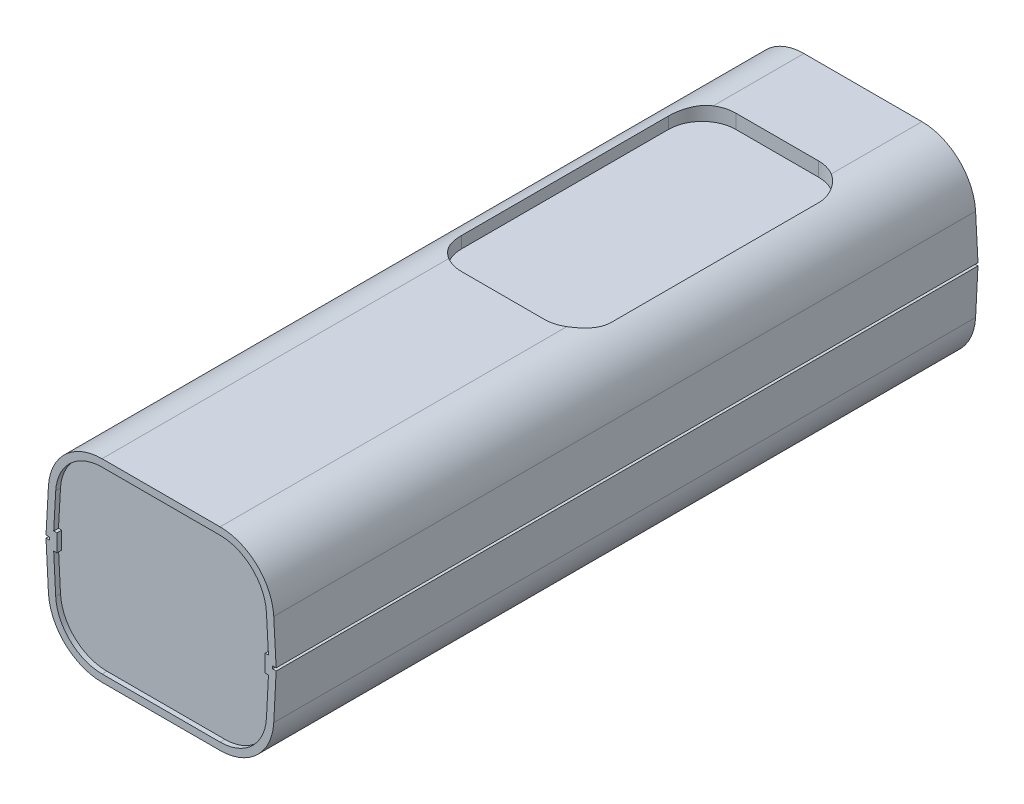
from build123d import *

# Parameters (mm, degrees)
MAIN_BODY_DEPTH  = 77
LENS_CUT_DEPTH   = 3.1
END_RECESS_START = -77
END_RECESS_DEPTH = 1.05


with BuildPart() as part:
    # main_features_sketch → main_body (new, symmetric)
    with BuildSketch(Plane.XY):
        with BuildLine():
            ThreePointArc((24.721981093, -10.075200948), (21.063236898, -18.011630623), (12.946199947, -21.25))
            Line((12.946199947, -21.25), (-12.946199947, -21.25))
            ThreePointArc((-12.946199947, -21.25), (-21.063236898, -18.011630623), (-24.721981093, -10.075200948))
            Line((-24.721981093, -10.075200948), (-25.25, 0))
            Line((-25.25, 0), (-24.45, 0))
            Line((-24.45, 0), (-24.45, 0.6))
            Line((-24.45, 0.6), (-25.25, 0.6))
            Line((-25.25, 0.6), (-24.719878978, 10.11408323))
            ThreePointArc((-24.719878978, 10.11408323), (-21.049103134, 18.025020906), (-12.946199947, 21.25))
            Line((-12.946199947, 21.25), (12.946199947, 21.25))
            ThreePointArc((12.946199947, 21.25), (21.049103134, 18.025020906), (24.719878978, 10.11408323))
            Line((24.719878978, 10.11408323), (25.25, 0.6))
            Line((25.25, 0.6), (24.45, 0.6))
            Line((24.45, 0.6), (24.45, 0))
            Line((24.45, 0), (25.25, 0))
            Line((25.25, 0), (24.721981093, -10.075200948))
        make_face()
        with BuildLine():
            ThreePointArc((-23.124173837, -9.991463418), (-19.961869577, -16.85103163), (-12.946199947, -19.65))
            Line((-12.946199947, -19.65), (12.946199947, -19.65))
            ThreePointArc((12.946199947, -19.65), (19.961869577, -16.85103163), (23.124173837, -9.991463418))
            Line((23.124173837, -9.991463418), (23.5639518, -1.6))
            Line((23.5639518, -1.6), (22.85, -1.6))
            Line((22.85, -1.6), (22.85, 2.2))
            Line((22.85, 2.2), (23.558366806, 2.2))
            Line((23.558366806, 2.2), (23.12235695, 10.025069924))
            ThreePointArc((23.12235695, 10.025069924), (19.949653565, 16.86260504), (12.946199947, 19.65))
            Line((12.946199947, 19.65), (-12.946199947, 19.65))
            ThreePointArc((-12.946199947, 19.65), (-19.949653565, 16.86260504), (-23.12235695, 10.025069924))
            Line((-23.12235695, 10.025069924), (-23.558366806, 2.2))
            Line((-23.558366806, 2.2), (-22.85, 2.2))
            Line((-22.85, 2.2), (-22.85, -1.6))
            Line((-22.85, -1.6), (-23.5639518, -1.6))
            Line((-23.5639518, -1.6), (-23.124173837, -9.991463418))
        make_face(mode=Mode.SUBTRACT)
        with BuildLine():
            Line((-23.5639518, -1.6), (-23.124173837, -9.991463418))
            ThreePointArc((-23.124173837, -9.991463418), (-19.961869577, -16.85103163), (-12.946199947, -19.65))
            Line((-12.946199947, -19.65), (12.946199947, -19.65))
            ThreePointArc((12.946199947, -19.65), (19.961869577, -16.85103163), (23.124173837, -9.991463418))
            Line((23.124173837, -9.991463418), (23.5639518, -1.6))
            Line((23.5639518, -1.6), (22.85, -1.6))
            Line((22.85, -1.6), (22.85, 2.2))
            Line((22.85, 2.2), (23.558366806, 2.2))
            Line((23.558366806, 2.2), (23.12235695, 10.025069924))
            ThreePointArc((23.12235695, 10.025069924), (19.949653565, 16.86260504), (12.946199947, 19.65))
            Line((12.946199947, 19.65), (-12.946199947, 19.65))
            ThreePointArc((-12.946199947, 19.65), (-19.949653565, 16.86260504), (-23.12235695, 10.025069924))
            Line((-23.12235695, 10.025069924), (-23.558366806, 2.2))
            Line((-23.558366806, 2.2), (-22.85, 2.2))
            Line((-22.85, 2.2), (-22.85, -1.6))
            Line((-22.85, -1.6), (-23.5639518, -1.6))
        make_face()
    extrude(amount=MAIN_BODY_DEPTH, both=True)

    # lens_sketch → lens_cut (cut)
    with BuildSketch(Plane(origin=(0, 21.25, 0), x_dir=(1, 0, 0), z_dir=(0, 1, 0))):
        with BuildLine():
            Line((9.085700376, 58.2), (-9.085700376, 58.2))
            ThreePointArc((-9.085700376, 58.2), (-14.310724248, 56.035724248), (-16.475, 50.810700376))
            Line((-16.475, 50.810700376), (-16.475, 5.389299624))
            ThreePointArc((-16.475, 5.389299624), (-14.310724248, 0.164275752), (-9.085700376, -2))
            Line((-9.085700376, -2), (9.085700376, -2))
            ThreePointArc((9.085700376, -2), (14.310724248, 0.164275752), (16.475, 5.389299624))
            Line((16.475, 5.389299624), (16.475, 50.810700376))
            ThreePointArc((16.475, 50.810700376), (14.310724248, 56.035724248), (9.085700376, 58.2))
        make_face()
    extrude(amount=-LENS_CUT_DEPTH, mode=Mode.SUBTRACT)

    # Sketch1_3 → end_recess (cut)
    with BuildSketch(Plane.XY.offset(END_RECESS_START)):
        with BuildLine():
            Line((-23.5639518, -1.6), (-23.124173837, -9.991463418))
            ThreePointArc((-23.124173837, -9.991463418), (-19.961869577, -16.85103163), (-12.946199947, -19.65))
            Line((-12.946199947, -19.65), (12.946199947, -19.65))
            ThreePointArc((12.946199947, -19.65), (19.961869577, -16.85103163), (23.124173837, -9.991463418))
            Line((23.124173837, -9.991463418), (23.5639518, -1.6))
            Line((23.5639518, -1.6), (22.85, -1.6))
            Line((22.85, -1.6), (22.85, 2.2))
            Line((22.85, 2.2), (23.558366806, 2.2))
            Line((23.558366806, 2.2), (23.12235695, 10.025069924))
            ThreePointArc((23.12235695, 10.025069924), (19.949653565, 16.86260504), (12.946199947, 19.65))
            Line((12.946199947, 19.65), (-12.946199947, 19.65))
            ThreePointArc((-12.946199947, 19.65), (-19.949653565, 16.86260504), (-23.12235695, 10.025069924))
            Line((-23.12235695, 10.025069924), (-23.558366806, 2.2))
            Line((-23.558366806, 2.2), (-22.85, 2.2))
            Line((-22.85, 2.2), (-22.85, -1.6))
            Line((-22.85, -1.6), (-23.5639518, -1.6))
        make_face()
    end_recess = extrude(amount=END_RECESS_DEPTH, mode=Mode.SUBTRACT)

    # end_recess_2: end_recess across plane
    add(end_recess.mirror(Plane.XY), mode=Mode.SUBTRACT)


solid = part.part
